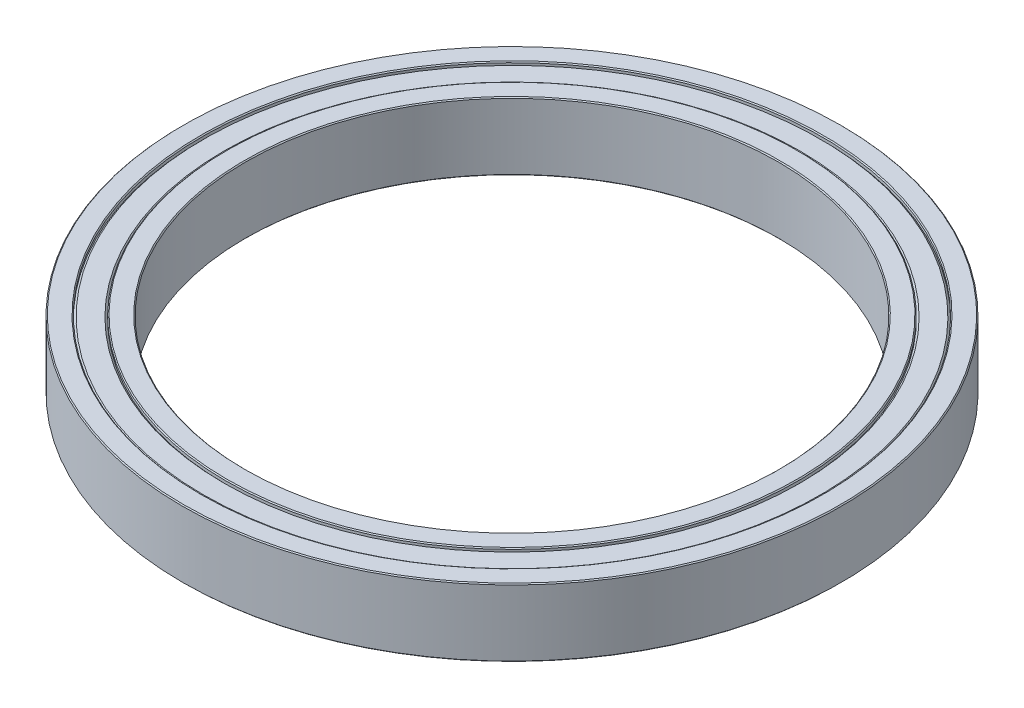
from build123d import *

# Parameters (mm, degrees)
SKETCH1_W     = 6.5
SKETCH1_H     = 7
CHAMFER1_SIZE = 0.1


with BuildPart() as part:
    # Sketch1 → Revolve1 (revolve)
    with BuildSketch(Plane(origin=(0, 0, 0), x_dir=(0, 0, -1), z_dir=(1, 0, 0))):
        with Locations((30.75, 0)):
            Rectangle(SKETCH1_W, SKETCH1_H)
    revolve(axis=Axis((0, 3.5, 0), (0, -1, 0)))

    # Sketch3 → Cut-Revolve2 (revolve, cut)
    with BuildSketch(Plane(origin=(0, 0, 0), x_dir=(0, 0, -1), z_dir=(1, 0, 0))):
        Polygon((31.8, 3.3), (32, 3.1), (32, 3.5), (29.5, 3.5), (29.5, 3.1), (29.7, 3.3), align=None)
    cut_revolve2 = revolve(axis=Axis((0, 3.5, 0), (0, -1, 0)), mode=Mode.SUBTRACT)

    # Mirror1: Cut-Revolve2 across plane
    add(cut_revolve2.mirror(Plane.ZX), mode=Mode.SUBTRACT)

    # Chamfer1
    chamfer1_edges = [part.edges().sort_by_distance(p)[0] for p in [
        (0, 3.5, 32),
        (0, 3.5, 29.5),
        (0, -3.5, 32),
        (0, -3.5, 29.5),
        (0, 3.5, 34),
        (0, -3.5, 34),
        (0, -3.5, 27.5),
        (0, 3.5, 27.5),
    ]]
    chamfer(chamfer1_edges, length=CHAMFER1_SIZE)


solid = part.part
